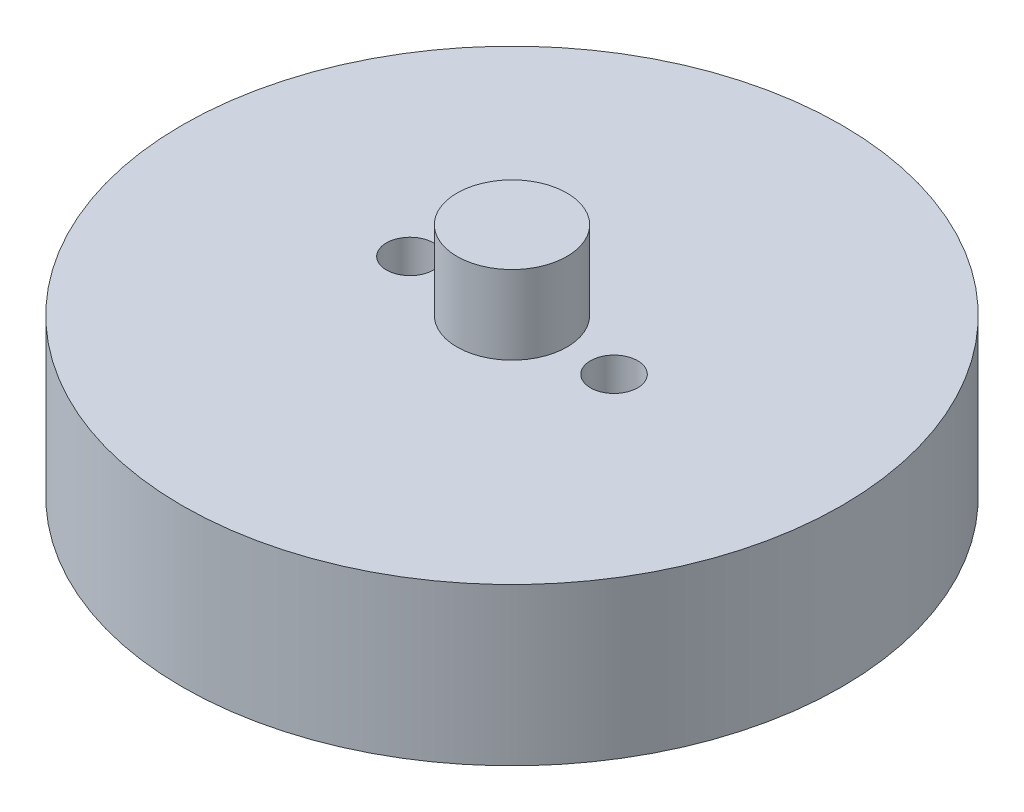
from build123d import *

# Parameters (mm, degrees)
SKETCH_1_R      = 21
SKETCH_1_R_2    = 1.5
EXTRUDE_1_DEPTH = 10
SKETCH_2_R      = 3.5
EXTRUDE_2_DEPTH = 5


with BuildPart() as part:
    # 草图1 → 凸台-拉伸1 (new body)
    with BuildSketch(Plane(origin=(0, 0, 0), x_dir=(1, 0, 0), z_dir=(0, 1, 0))):
        Circle(SKETCH_1_R)
        with Locations((-6.5, 0)):
            Circle(SKETCH_1_R_2, mode=Mode.SUBTRACT)
        with Locations((6.5, 0)):
            Circle(SKETCH_1_R_2, mode=Mode.SUBTRACT)
    extrude(amount=EXTRUDE_1_DEPTH)

    # 草图2 → 凸台-拉伸2 (add)
    with BuildSketch(Plane(origin=(0, 10, 0), x_dir=(1, 0, 0), z_dir=(0, 1, 0))):
        Circle(SKETCH_2_R)
    extrude(amount=EXTRUDE_2_DEPTH)


solid = part.part
